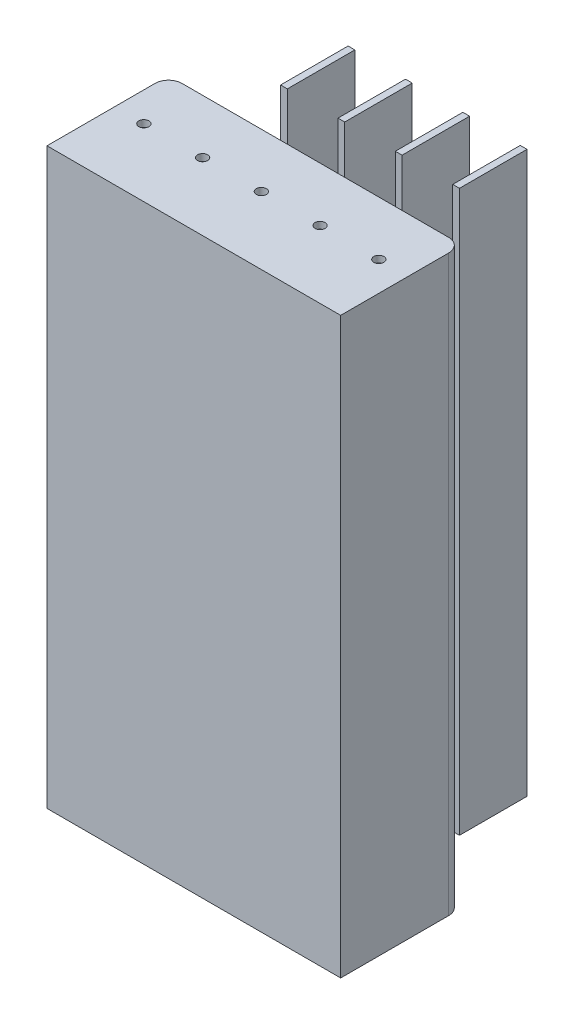
from build123d import *

# Parameters (mm, degrees)
SKETCH1_W                      = 87
SKETCH1_H                      = 170
BOSS_EXTRUDE1_DEPTH            = 22
SHELL1_T                       = -2
SKETCH2_W                      = 2
SKETCH2_H                      = 165.999999995
EXTRUDE_THIN2_DEPTH            = 20
EXTRUDE_THIN2_2_DEPTH          = 20
EXTRUDE_THIN2_3_DEPTH          = 20
EXTRUDE_THIN2_4_DEPTH          = 20
SKETCH5_W                      = 1.5
SKETCH5_H                      = 2
F_3_0MM_DOWEL_HOLE1_AT_2_COUNT = 2
F_3_0MM_DOWEL_HOLE1_AT_2_PITCH = 17.4
F_3_0MM_DOWEL_HOLE1_AT_3_COUNT = 2
F_3_0MM_DOWEL_HOLE1_AT_3_PITCH = 34.8
F_3_0MM_DOWEL_HOLE1_AT_4_COUNT = 2
F_3_0MM_DOWEL_HOLE1_AT_4_PITCH = 52.2
F_3_0MM_DOWEL_HOLE1_AT_5_COUNT = 2
F_3_0MM_DOWEL_HOLE1_AT_5_PITCH = 69.6
SKETCH7_W                      = 87
SKETCH7_H                      = 170
BOSS_EXTRUDE2_DEPTH            = 5
FILLET1_R                      = 4
SKETCH6_W                      = 87
SKETCH6_H                      = 170
BOSS_EXTRUDE3_DEPTH            = 9


with BuildPart() as part:
    # Sketch1 → Boss-Extrude1 (new body)
    with BuildSketch(Plane.XY.offset(5)):
        with Locations((217.379927846, -194.578074772)):
            Rectangle(SKETCH1_W, SKETCH1_H)
    extrude(amount=BOSS_EXTRUDE1_DEPTH)

    # Shell1
    shell1_openings = [part.faces().sort_by_distance(p)[0] for p in [
        (217.379927846, -194.578074772, 27),
    ]]
    offset(amount=SHELL1_T, openings=shell1_openings, kind=Kind.INTERSECTION)

    # Sketch5 → Ø3.0mm Dowel Hole1 (revolve, cut)
    with BuildSketch(Plane(origin=(182.579927846, -109.578074772, 16), x_dir=(0, 0, 1), z_dir=(1, 0, 0))):
        with Locations((0.75, 1)):
            Rectangle(SKETCH5_W, SKETCH5_H)
    f_3_0mm_dowel_hole1 = revolve(axis=Axis((182.579927846, -103.228074772, 16), (0, -1, 0)), mode=Mode.SUBTRACT)

    # Ø3.0mm Dowel Hole1 at 2: Ø3.0mm Dowel Hole1 ×2
    with Locations(*[(i * F_3_0MM_DOWEL_HOLE1_AT_2_PITCH, 0, 0) for i in range(1, F_3_0MM_DOWEL_HOLE1_AT_2_COUNT)]):
        add(f_3_0mm_dowel_hole1, mode=Mode.SUBTRACT)

    # Ø3.0mm Dowel Hole1 at 3: Ø3.0mm Dowel Hole1 ×2
    with Locations(*[(i * F_3_0MM_DOWEL_HOLE1_AT_3_PITCH, 0, 0) for i in range(1, F_3_0MM_DOWEL_HOLE1_AT_3_COUNT)]):
        add(f_3_0mm_dowel_hole1, mode=Mode.SUBTRACT)

    # Ø3.0mm Dowel Hole1 at 4: Ø3.0mm Dowel Hole1 ×2
    with Locations(*[(i * F_3_0MM_DOWEL_HOLE1_AT_4_PITCH, 0, 0) for i in range(1, F_3_0MM_DOWEL_HOLE1_AT_4_COUNT)]):
        add(f_3_0mm_dowel_hole1, mode=Mode.SUBTRACT)

    # Ø3.0mm Dowel Hole1 at 5: Ø3.0mm Dowel Hole1 ×2
    with Locations(*[(i * F_3_0MM_DOWEL_HOLE1_AT_5_PITCH, 0, 0) for i in range(1, F_3_0MM_DOWEL_HOLE1_AT_5_COUNT)]):
        add(f_3_0mm_dowel_hole1, mode=Mode.SUBTRACT)

    # Sketch7 → Boss-Extrude2 (add)
    with BuildSketch(Plane.XY):
        with Locations((217.379927846, -194.578074772)):
            Rectangle(SKETCH7_W, SKETCH7_H)
    extrude(amount=BOSS_EXTRUDE2_DEPTH)

    # Fillet1
    fillet1_edges = [part.edges().sort_by_distance(p)[0] for p in [
        (173.879927846, -194.578074772, 0),
        (260.879927846, -194.578074772, 0),
    ]]
    fillet(fillet1_edges, radius=FILLET1_R)

    # Sketch6 → Boss-Extrude3 (add)
    with BuildSketch(Plane.XY.offset(27)):
        with Locations((217.379927846, -194.578074772)):
            Rectangle(SKETCH6_W, SKETCH6_H)
    extrude(amount=BOSS_EXTRUDE3_DEPTH)


with BuildPart() as body_2:
    # Sketch2 → Extrude-Thin2 (new body)
    with BuildSketch(Plane(origin=(0, 0.00031469, -36.195723728), x_dir=(1, 0, 0), z_dir=(0, -7.966e-06, 1))):
        with Locations((191.879927846, -194.577886062)):
            Rectangle(SKETCH2_W, SKETCH2_H)
    extrude(amount=EXTRUDE_THIN2_DEPTH)


with BuildPart() as body_3:
    # Sketch2 → Extrude-Thin2 2 (new body)
    with BuildSketch(Plane(origin=(0, 0.00031469, -36.195723728), x_dir=(1, 0, 0), z_dir=(0, -7.966e-06, 1))):
        with Locations((208.879927846, -194.577886062)):
            Rectangle(SKETCH2_W, SKETCH2_H)
    extrude(amount=EXTRUDE_THIN2_2_DEPTH)


with BuildPart() as body_4:
    # Sketch2 → Extrude-Thin2 3 (new body)
    with BuildSketch(Plane(origin=(0, 0.00031469, -36.195723728), x_dir=(1, 0, 0), z_dir=(0, -7.966e-06, 1))):
        with Locations((225.879927846, -194.577886062)):
            Rectangle(SKETCH2_W, SKETCH2_H)
    extrude(amount=EXTRUDE_THIN2_3_DEPTH)


with BuildPart() as body_5:
    # Sketch2 → Extrude-Thin2 4 (new body)
    with BuildSketch(Plane(origin=(0, 0.00031469, -36.195723728), x_dir=(1, 0, 0), z_dir=(0, -7.966e-06, 1))):
        with Locations((242.879927846, -194.577886062)):
            Rectangle(SKETCH2_W, SKETCH2_H)
    extrude(amount=EXTRUDE_THIN2_4_DEPTH)


solid = Compound([part.part, body_2.part, body_3.part, body_4.part, body_5.part])
